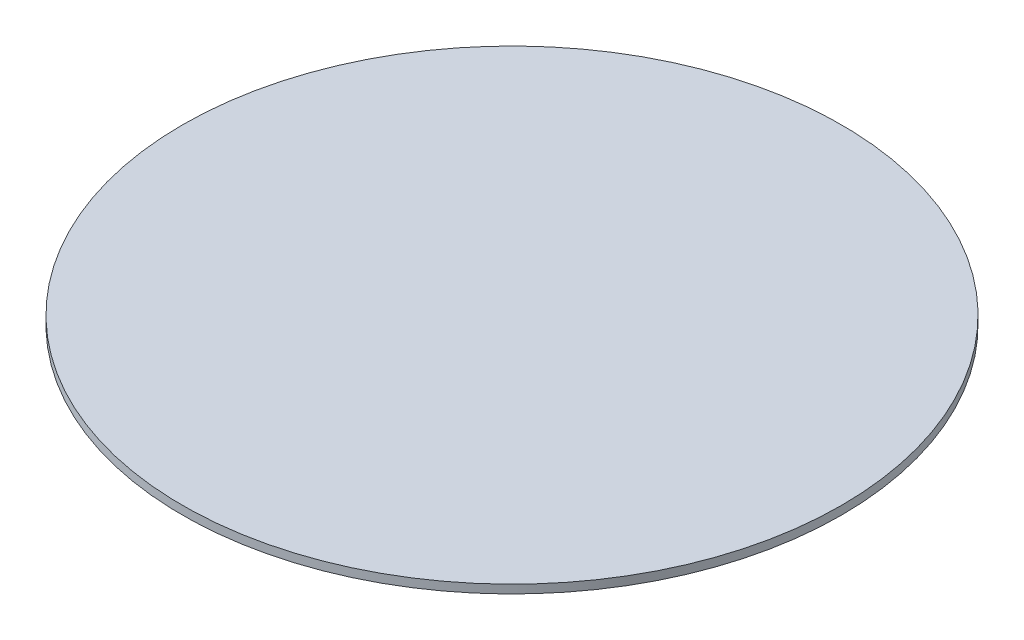
from build123d import *

# Parameters (mm, degrees)
SKETCH4_R           = 194
BOSS_EXTRUDE2_DEPTH = 5


with BuildPart() as part:
    # Sketch4 → Boss-Extrude2 (new body)
    with BuildSketch(Plane(origin=(0, 0, 0), x_dir=(1, 0, 0), z_dir=(0, 1, 0))):
        with Locations(Location((0, 0, 0), (0, 0, 180))):
            Circle(SKETCH4_R)
    extrude(amount=BOSS_EXTRUDE2_DEPTH)


solid = part.part
